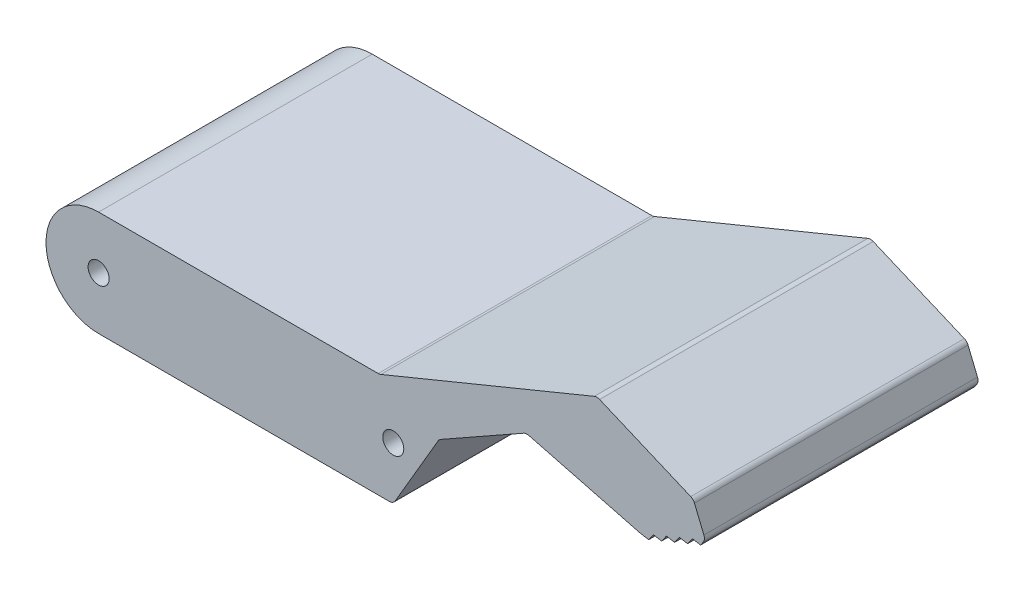
from build123d import *

# Parameters (mm, degrees)
SKETCH1_R           = 1.5
BOSS_EXTRUDE1_DEPTH = 39
FILLET1_R           = 1


with BuildPart() as part:
    # Sketch1 → Boss-Extrude1 (new body)
    with BuildSketch(Plane.XY):
        with BuildLine():
            Line((40.05, 7.5), (0, 7.5))
            ThreePointArc((0, 7.5), (-7.5, 0), (0, -7.5))
            Line((0, -7.5), (42, -7.5))
            Line((42, -7.5), (48.530525776, 3.688120536))
            ThreePointArc((48.530525776, 3.688120536), (45.780813139, 6.477302835), (42, 7.5))
            Line((42, 7.5), (40.05, 7.5))
        make_face()
        Circle(SKETCH1_R, mode=Mode.SUBTRACT)
        with Locations((42, 0)):
            Circle(SKETCH1_R, mode=Mode.SUBTRACT)
        with BuildLine():
            Line((71.033420644, 20.238824327), (40.05, 7.5))
            Line((40.05, 7.5), (42, 7.5))
            ThreePointArc((42, 7.5), (45.780813139, 6.477302835), (48.530525776, 3.688120536))
            Line((48.530525776, 3.688120536), (60.929817382, 10.690632061))
            Line((60.929817382, 10.690632061), (77.239530905, 6.459175571))
            Line((77.239530905, 6.459175571), (78.403975083, 6.2567657))
            Line((78.403975083, 6.2567657), (79.089287361, 7.219702396))
            Line((79.089287361, 7.219702396), (80.253731539, 7.017292525))
            Line((80.253731539, 7.017292525), (80.939043817, 7.980229222))
            Line((80.939043817, 7.980229222), (82.103487996, 7.777819351))
            Line((82.103487996, 7.777819351), (82.788800274, 8.740756047))
            Line((82.788800274, 8.740756047), (83.953244452, 8.538346176))
            Line((83.953244452, 8.538346176), (84.63855673, 9.501282873))
            Line((84.63855673, 9.501282873), (85.803000908, 9.298873002))
            Line((85.803000908, 9.298873002), (86.488313186, 10.261809698))
            Line((86.488313186, 10.261809698), (84.777127829, 14.423761725))
            Line((84.777127829, 14.423761725), (71.033420644, 20.238824327))
        make_face()
    extrude(amount=BOSS_EXTRUDE1_DEPTH)

    # Fillet1
    fillet1_edges = [part.edges().sort_by_distance(p)[0] for p in [
        (42, -7.5, 19.5),
        (40.05, 7.5, 19.5),
        (71.033420644, 20.238824327, 19.5),
        (84.777127829, 14.423761725, 19.5),
        (86.488313186, 10.261809698, 19.5),
        (77.239530905, 6.459175571, 19.5),
        (60.929817382, 10.690632061, 19.5),
        (48.530525776, 3.688120536, 19.5),
    ]]
    fillet(fillet1_edges, radius=FILLET1_R)


solid = part.part
